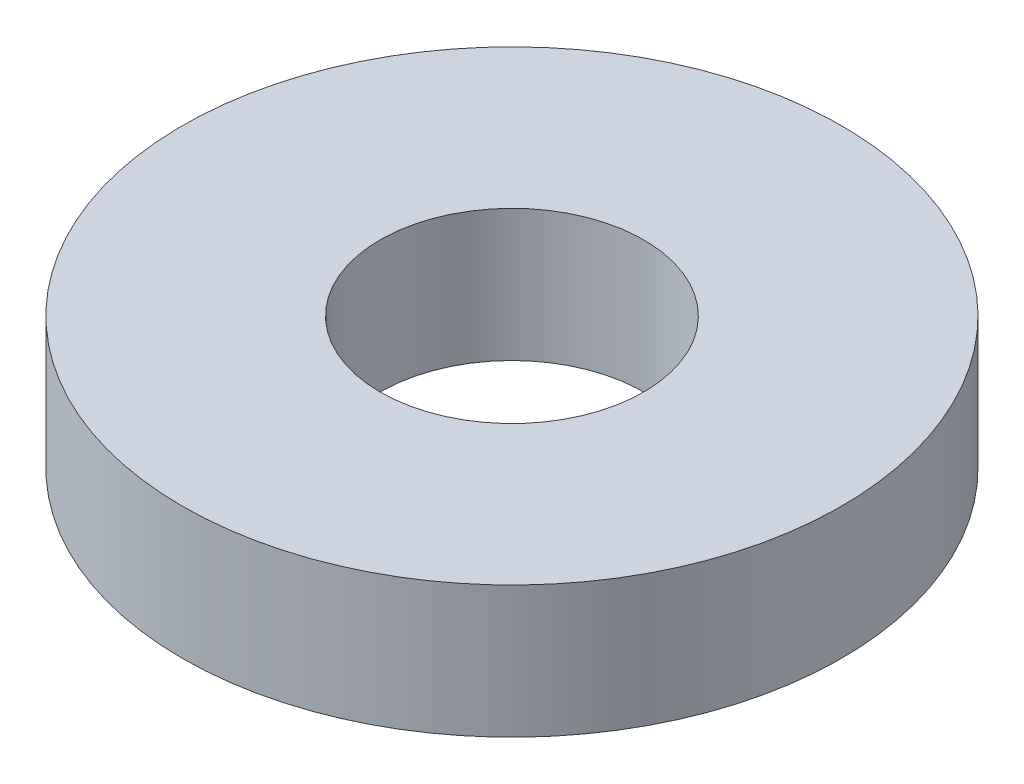
from build123d import *

# Parameters (mm, degrees)
SKETCH1_R           = 12.5
SKETCH1_R_2         = 5
BOSS_EXTRUDE1_DEPTH = 5


with BuildPart() as part:
    # Sketch1 → Boss-Extrude1 (new body)
    with BuildSketch(Plane(origin=(0, 0, 0), x_dir=(1, 0, 0), z_dir=(0, 1, 0))):
        Circle(SKETCH1_R)
        Circle(SKETCH1_R_2, mode=Mode.SUBTRACT)
    extrude(amount=BOSS_EXTRUDE1_DEPTH)


solid = part.part
